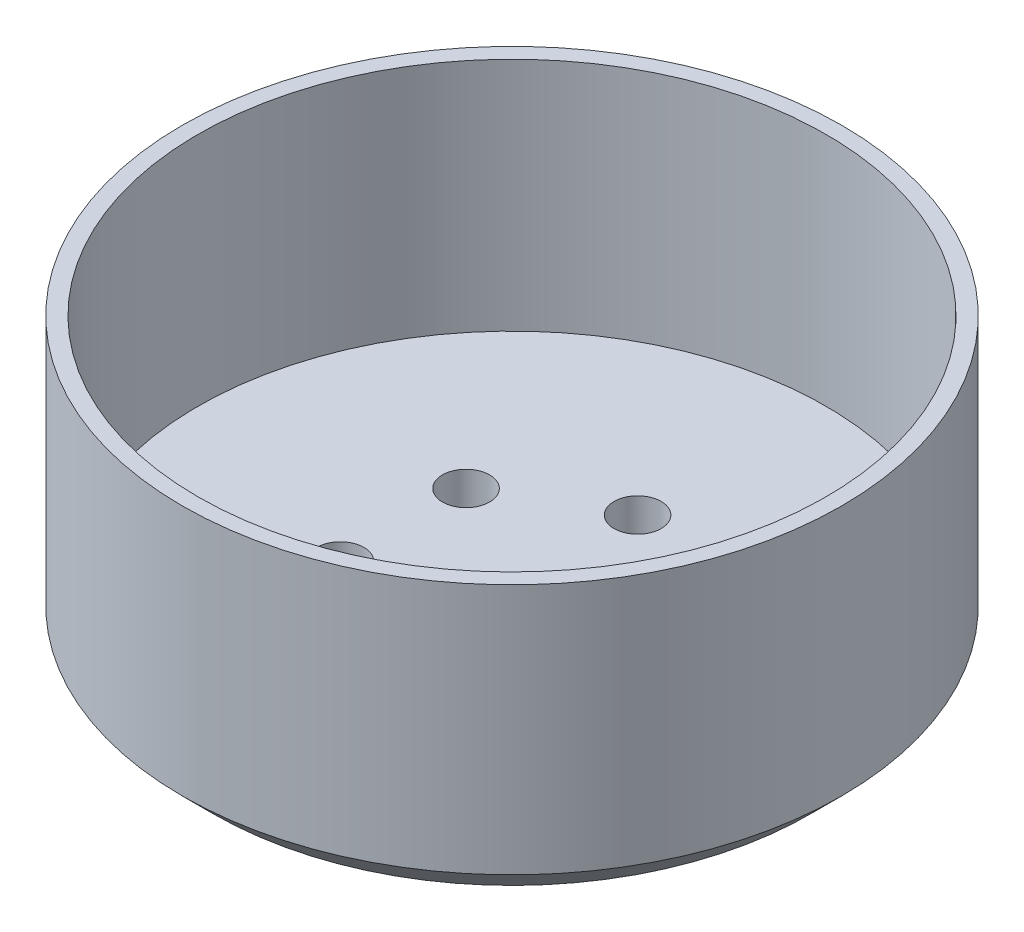
from build123d import *

# Parameters (mm, degrees)
SKETCH_1_R          = 20
EXTRUDE_1_DEPTH     = 3
SKETCH_1_3_R        = 21
SKETCH_1_3_R_2      = 20
EXTRUDE_2_DEPTH     = 18
SKETCH_4_R          = 1.5
CUT_EXTRUDE_1_DEPTH = 17
SKETCH_5_R          = 3.5
EXTRUDE_3_DEPTH     = 1


with BuildPart() as part:
    # Sketch 1 → Extrude 1 (new body)
    with BuildSketch(Plane(origin=(0, 0, 0), x_dir=(1, 0, 0), z_dir=(0, 1, 0))):
        Circle(SKETCH_1_R)
    extrude(amount=EXTRUDE_1_DEPTH)

    # Sketch 1_3 → Extrude 2 (add)
    with BuildSketch(Plane(origin=(0, 0, 0), x_dir=(1, 0, 0), z_dir=(0, 1, 0))):
        Circle(SKETCH_1_3_R)
        Circle(SKETCH_1_3_R_2, mode=Mode.SUBTRACT)
    extrude(amount=EXTRUDE_2_DEPTH)

    # Sketch 3 → Cut-Revolve 1 (revolve, cut)
    with BuildSketch(Plane.XY):
        Polygon((19, 0), (21, 2), (21, 0), align=None)
    revolve(axis=Axis((0, 18, 0), (0, -1, 0)), mode=Mode.SUBTRACT)

    # Sketch 4 → Cut-Extrude 1 (cut)
    with BuildSketch(Plane.XZ):
        with Locations((0, 8)):
            Circle(SKETCH_4_R)
        with Locations((6.92820323, 4)):
            Circle(SKETCH_4_R)
        with Locations((6.92820323, -4)):
            Circle(SKETCH_4_R)
        with Locations((0, -8)):
            Circle(SKETCH_4_R)
        with Locations((-6.92820323, -4)):
            Circle(SKETCH_4_R)
        with Locations((-6.92820323, 4)):
            Circle(SKETCH_4_R)
    extrude(amount=-CUT_EXTRUDE_1_DEPTH, mode=Mode.SUBTRACT)

    # Sketch 5 → Extrude 3 (add)
    with BuildSketch(Plane.XZ):
        Circle(SKETCH_5_R)
    extrude(amount=EXTRUDE_3_DEPTH)


solid = part.part
